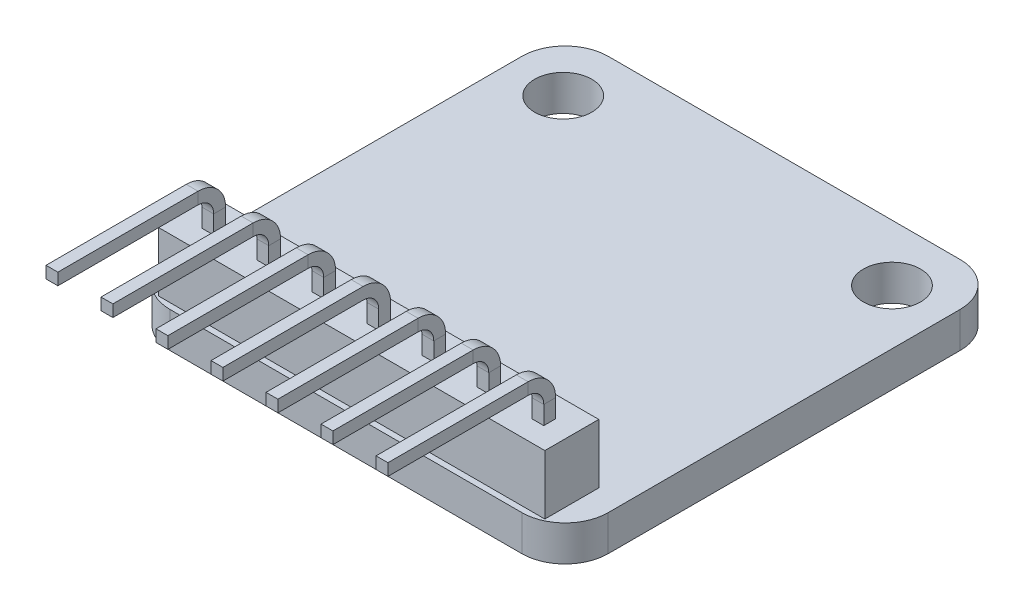
from build123d import *

# Parameters (mm, degrees)
SKETCH2_W           = 20.32
SKETCH2_H           = 20.32
SKETCH2_R           = 1.325
BOSS_EXTRUDE1_DEPTH = 1.65
SKETCH3_W           = 0.55
SKETCH3_H           = 0.55
LPATTERN1_COUNT     = 4
LPATTERN1_PITCH     = 2.55
LPATTERN1_COL_COUNT = 4
LPATTERN1_COL_PITCH = 2.55
SKETCH5_W           = 17.9
SKETCH5_H           = 2.5
BOSS_EXTRUDE2_DEPTH = 2.75
SKETCH6_W           = 2
SKETCH6_H           = 2.5
SKETCH6_W_2         = 2.5
SKETCH6_H_2         = 3.5
BOSS_EXTRUDE3_DEPTH = 0.5
FILLET1_R           = 2
SKETCH7_W           = 1.7
SKETCH7_H           = 2.7
CUT_EXTRUDE1_DEPTH  = 0.1


with BuildPart() as part:
    # Sketch2 → Boss-Extrude1 (new body)
    with BuildSketch(Plane(origin=(0, 0, 0), x_dir=(1, 0, 0), z_dir=(0, 1, 0))):
        with Locations((10.16, 10.16)):
            Rectangle(SKETCH2_W, SKETCH2_H)
        with Locations((2.54, 17.695)):
            Circle(SKETCH2_R, mode=Mode.SUBTRACT)
        with Locations((17.78, 17.695)):
            Circle(SKETCH2_R, mode=Mode.SUBTRACT)
    extrude(amount=BOSS_EXTRUDE1_DEPTH)

    # Sweep1: sweep along a path in Sketch4
    with BuildLine(Plane(origin=(0, 0, 0), x_dir=(0, 0, -1), z_dir=(1, 0, 0))) as sweep1_path:
        Line((1.524, 1.65), (1.524, 5.25))
        ThreePointArc((1.524, 5.25), (1.231106781, 5.957106781), (0.524, 6.25))
        Line((0.524, 6.25), (-5.976, 6.25))
    # Sketch3 → Sweep1 (sweep)
    with BuildSketch(Plane(origin=(0, 1.65, 0), x_dir=(1, 0, 0), z_dir=(0, 1, 0))):
        with Locations((10.16, 1.524)):
            Rectangle(SKETCH3_W, SKETCH3_H)
    sweep1 = sweep(path=sweep1_path.line)

    # LPattern1: Sweep1 ×4
    with Locations(*[(-i * LPATTERN1_PITCH, 0, 0) for i in range(1, LPATTERN1_COUNT)]):
        add(sweep1)

    # LPattern1 col: Sweep1 ×4
    with Locations(*[(i * LPATTERN1_COL_PITCH, 0, 0) for i in range(1, LPATTERN1_COL_COUNT)]):
        add(sweep1)

    # Sketch5 → Boss-Extrude2 (add)
    with BuildSketch(Plane(origin=(0, 1.65, 0), x_dir=(1, 0, 0), z_dir=(0, 1, 0))):
        with Locations((10.16, 1.524)):
            Rectangle(SKETCH5_W, SKETCH5_H)
    extrude(amount=BOSS_EXTRUDE2_DEPTH)

    # Sketch6 → Boss-Extrude3 (add)
    with BuildSketch(Plane.XZ):
        with Locations((9.906, -9.906)):
            Rectangle(SKETCH6_W, SKETCH6_H)
        with Locations((13.208, -10.406)):
            Rectangle(SKETCH6_W_2, SKETCH6_H_2)
    extrude(amount=BOSS_EXTRUDE3_DEPTH)

    # Fillet1
    fillet1_edges = [part.edges().sort_by_distance(p)[0] for p in [
        (0, 0.825, -20.32),
        (20.32, 0.825, -20.32),
        (20.32, 0.825, 0),
        (0, 0.825, 0),
    ]]
    fillet(fillet1_edges, radius=FILLET1_R)

    # Sketch7 → Cut-Extrude1 (cut)
    with BuildSketch(Plane.XZ.offset(0.5)):
        with Locations((13.208, -10.406)):
            Rectangle(SKETCH7_W, SKETCH7_H)
    extrude(amount=-CUT_EXTRUDE1_DEPTH, mode=Mode.SUBTRACT)


solid = part.part
